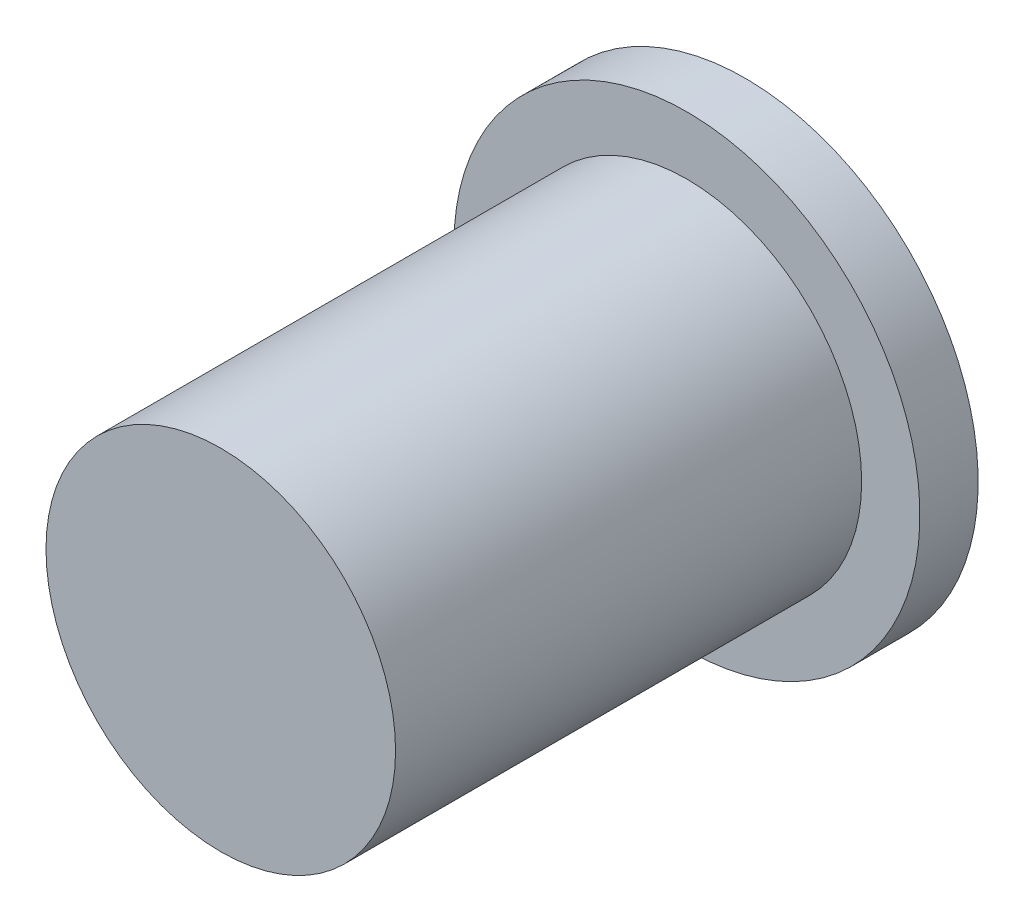
from build123d import *

# Parameters (mm, degrees)
SKETCH1_R           = 15
BOSS_EXTRUDE1_DEPTH = 40
SKETCH2_R           = 20
BOSS_EXTRUDE2_DEPTH = 5


with BuildPart() as part:
    # Sketch1 → Boss-Extrude1 (new body)
    with BuildSketch(Plane.XY):
        Circle(SKETCH1_R)
    extrude(amount=BOSS_EXTRUDE1_DEPTH)

    # Sketch2 → Boss-Extrude2 (add)
    with BuildSketch(Plane(origin=(0, 0, 0), x_dir=(-1, 0, 0), z_dir=(0, 0, -1))):
        Circle(SKETCH2_R)
    extrude(amount=BOSS_EXTRUDE2_DEPTH)


solid = part.part
